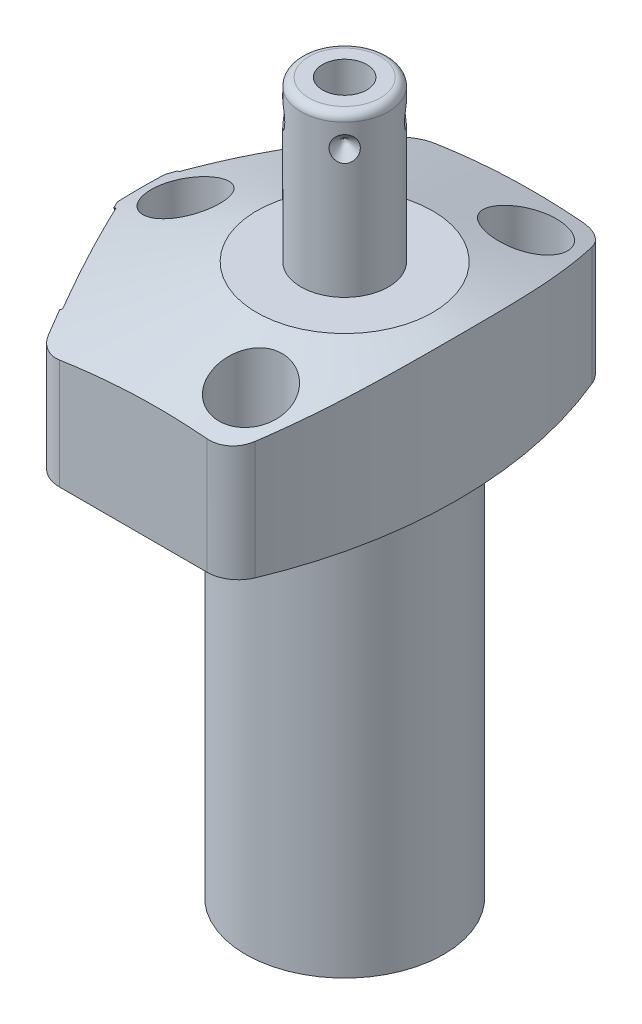
from build123d import *

# Parameters (mm, degrees)
CUT_EXTRUDE1_REACH = 21.05
CUT_EXTRUDE2_REACH = 21.05
S2D0002_OUTSIDE_W  = 78.27
S2D0002_OUTSIDE_H  = 69.906
CUT_EXTRUDE3_DEPTH = 26.035
FILLET1_R          = 3.9624
SKETCH17_R         = 10.4775
CUT_EXTRUDE4_DEPTH = 0.254
SKETCH18_R         = 10.4775
CUT_EXTRUDE5_DEPTH = 0.254
SKETCH19_R         = 5.5626
CUT_EXTRUDE6_DEPTH = 2.667
SKETCH12_R         = 4.8006
EXTRUDE1_DEPTH     = 1.651
EXTRUDE2_START     = -2.667
SKETCH13_R         = 4.8006
EXTRUDE2_DEPTH     = 2.667
CIRPATTERN1_COUNT  = 4
HOLE1_D            = 5.5626
HOLE1_DEPTH        = 19.05
HOLE1_CBORE_D      = 8.7122
HOLE1_CBORE_DEPTH  = 11.0998


with BuildPart() as part:
    # Sketch1 → Revolve1 (revolve)
    with BuildSketch(Plane(origin=(0, 0, 0), x_dir=(0, -1, 0), z_dir=(0, 0, 1)), mode=Mode.PRIVATE) as revolve1_sk:
        Polygon((0, 28.575), (-19.05, 28.575), (-19.05, 0), (50.8, 0), (50.8, 12.573), (0, 12.573), align=None)
    revolve(revolve1_sk.sketch.rotate(Axis((0, 22.5425, 0), (0, -1, 0)), 90), axis=Axis((0, 22.5425, 0), (0, -1, 0)))  # turned: the seam where the file's is

    # Sketch2 → Cut-Extrude1 (cut, up to next)
    with BuildSketch(Plane(origin=(0, 0, 0), x_dir=(0, 0, -1), z_dir=(0, -1, 0)), mode=Mode.PRIVATE) as cut_extrude1_sk1:
        with BuildLine():
            Line((23.8125, -15.795425564), (23.8125, 15.795425564))
            ThreePointArc((23.8125, 15.795425564), (28.575, 0), (23.8125, -15.795425564))
        make_face()
    cut_extrude1_tool1 = extrude(cut_extrude1_sk1.sketch, amount=-CUT_EXTRUDE1_REACH, mode=Mode.PRIVATE) & part.part
    add(cut_extrude1_tool1.solids().sort_by_distance((0, 0, -25.731798))[0], mode=Mode.SUBTRACT)
    # Sketch2 → Cut-Extrude1 (cut, up to next)
    with BuildSketch(Plane(origin=(0, 0, 0), x_dir=(0, 0, -1), z_dir=(0, -1, 0)), mode=Mode.PRIVATE) as cut_extrude1_sk2:
        with BuildLine():
            Line((-23.8125, 15.795425564), (-23.8125, -15.795425564))
            ThreePointArc((-23.8125, -15.795425564), (-28.575, 0), (-23.8125, 15.795425564))
        make_face()
    cut_extrude1_tool2 = extrude(cut_extrude1_sk2.sketch, amount=-CUT_EXTRUDE1_REACH, mode=Mode.PRIVATE) & part.part
    add(cut_extrude1_tool2.solids().sort_by_distance((0, 0, 25.731798))[0], mode=Mode.SUBTRACT)

    # Sketch3 → Cut-Extrude2 (cut, up to next)
    with BuildSketch(Plane(origin=(0, 0, 0), x_dir=(-1, 0, 0), z_dir=(0, -1, 0)), mode=Mode.PRIVATE) as cut_extrude2_sk1:
        with BuildLine():
            Line((14.75388632, 23.8125), (27.415217161, 0))
            Line((27.415217161, 0), (14.75388632, -23.8125))
            Line((14.75388632, -23.8125), (15.795425564, -23.8125))
            ThreePointArc((15.795425564, -23.8125), (28.575, 0), (15.795425564, 23.8125))
            Line((15.795425564, 23.8125), (14.75388632, 23.8125))
        make_face()
    cut_extrude2_tool1 = extrude(cut_extrude2_sk1.sketch, amount=-CUT_EXTRUDE2_REACH, mode=Mode.PRIVATE) & part.part
    add(cut_extrude2_tool1.solids().sort_by_distance((-15.274656, 0, -23.3166))[0], mode=Mode.SUBTRACT)

    # S2D0002 outside → Cut-Extrude3 (cut)
    with BuildSketch(Plane(origin=(0, 0, 0), x_dir=(-1, 0, 0), z_dir=(0, -1, 0))):
        with Locations((-0.58, 0)):
            Rectangle(S2D0002_OUTSIDE_W, S2D0002_OUTSIDE_H)
        with BuildLine():
            Line((25.8064, 53.379071452), (25.8064, -53.379071452))
            ThreePointArc((25.8064, -53.379071452), (-14.3002, 0), (25.8064, 53.379071452))
        make_face(mode=Mode.SUBTRACT)
    extrude(amount=-CUT_EXTRUDE3_DEPTH, mode=Mode.SUBTRACT)

    # Fillet1
    fillet1_edges = [part.edges().sort_by_distance(p)[0] for p in [
        (-14.75388632, 9.525, 23.8125),
        (-14.75388632, 9.525, -23.8125),
        (8.940213818, 9.525, 23.8125),
        (8.940213818, 9.525, -23.8125),
    ]]
    fillet(fillet1_edges, radius=FILLET1_R)

    # Sketch5 → Cut-Revolve1 (revolve, cut)
    with BuildSketch(Plane.XY, mode=Mode.PRIVATE) as cut_revolve1_sk:
        Polygon((-11.176, 19.05), (-44.45, 8.238622028), (-44.45, 19.05), align=None)
    revolve(cut_revolve1_sk.sketch.rotate(Axis((0, 5.998428823, 0), (0, 1, 0)), 90), axis=Axis((0, 5.998428823, 0), (0, 1, 0)), mode=Mode.SUBTRACT)  # turned: the seam where the file's is

    # Sketch6 → Cut-Revolve2 (revolve, cut)
    with BuildSketch(Plane(origin=(-21.148537334, 7.9502, -11.244876766), x_dir=(0.469471563, 0, -0.882947593), z_dir=(0, 1, 0))):
        Polygon((0, 0), (4.5466, 0), (4.106586662, -2.0701), (3.4544, -2.722286662), (3.4544, -12.192), (0, -12.192), align=None)
    revolve(axis=Axis((-9.845395429, 7.9502, -5.234889608), (-0.882947593, 0, -0.469471563)), mode=Mode.SUBTRACT)

    # Sketch7 → Cut-Revolve3 (revolve, cut)
    with BuildSketch(Plane(origin=(-21.148537334, 7.9502, 11.244876766), x_dir=(-0.469471563, 0, -0.882947593), z_dir=(0, 1, 0))):
        Polygon((0, 0), (4.5466, 0), (4.106586662, -2.0701), (3.4544, -2.722286662), (3.4544, -12.192), (0, -12.192), align=None)
    revolve(axis=Axis((-9.845395429, 7.9502, 5.234889608), (-0.882947593, 0, 0.469471563)), mode=Mode.SUBTRACT)

    # Sketch17 → Cut-Extrude4 (cut)
    with BuildSketch(Plane(origin=(-21.372806022, 0, 11.364122543), x_dir=(0.469471563, 0, 0.882947593), z_dir=(-0.882947593, 0, 0.469471563))):
        with Locations((0, 7.9502)):
            Circle(SKETCH17_R)
    extrude(amount=-CUT_EXTRUDE4_DEPTH, mode=Mode.SUBTRACT)

    # Sketch18 → Cut-Extrude5 (cut)
    with BuildSketch(Plane(origin=(-21.372806022, 0, -11.364122543), x_dir=(-0.469471563, 0, 0.882947593), z_dir=(-0.882947593, 0, -0.469471563))):
        with Locations((0, 7.9502)):
            Circle(SKETCH18_R)
    extrude(amount=-CUT_EXTRUDE5_DEPTH, mode=Mode.SUBTRACT)

    # Sketch8 → Cut-Revolve4 (revolve, cut)
    with BuildSketch(Plane(origin=(-11.1252, 2.667, -15.875), x_dir=(-1, 0, 0), z_dir=(0, 0, 1)), mode=Mode.PRIVATE) as cut_revolve4_sk:
        Polygon((0, 0), (4.5466, 0), (4.106586662, -2.0701), (3.4544, -2.722286662), (3.4544, -11.684), (0, -11.684), align=None)
    revolve(cut_revolve4_sk.sketch.rotate(Axis((-11.1252, 14.9352, -15.875), (0, -1, 0)), 270), axis=Axis((-11.1252, 14.9352, -15.875), (0, -1, 0)), mode=Mode.SUBTRACT)  # turned: the seam where the file's is

    # Sketch9 → Cut-Revolve5 (revolve, cut)
    with BuildSketch(Plane(origin=(-11.1252, 2.667, 15.875), x_dir=(-1, 0, 0), z_dir=(0, 0, 1)), mode=Mode.PRIVATE) as cut_revolve5_sk:
        Polygon((0, 0), (4.5466, 0), (4.106586662, -2.0701), (3.4544, -2.722286662), (3.4544, -11.684), (0, -11.684), align=None)
    revolve(cut_revolve5_sk.sketch.rotate(Axis((-11.1252, 14.9352, 15.875), (0, -1, 0)), 270), axis=Axis((-11.1252, 14.9352, 15.875), (0, -1, 0)), mode=Mode.SUBTRACT)  # turned: the seam where the file's is

    # Sketch10 → Revolve2 (revolve)
    with BuildSketch(Plane(origin=(0, 0, 0), x_dir=(0, 0, -1), z_dir=(1, 0, 0)), mode=Mode.PRIVATE) as revolve2_sk:
        with BuildLine():
            Line((0, 19.05), (-5.55625, 19.05))
            Line((-5.55625, 19.05), (-5.55625, 38.3032))
            ThreePointArc((-5.55625, 38.3032), (-5.25867049, 39.02162049), (-4.54025, 39.3192))
            Line((-4.54025, 39.3192), (0, 39.3192))
            Line((0, 39.3192), (0, 19.05))
        make_face()
    revolve(revolve2_sk.sketch.rotate(Axis((0, 18.03654, 0), (0, 1, 0)), 180), axis=Axis((0, 18.03654, 0), (0, 1, 0)))  # turned: the seam where the file's is

    # Sketch19 → Cut-Extrude6 (cut)
    with BuildSketch(Plane.XZ):
        with Locations(Location((-11.1252, -15.875, 0), (0, 0, 270))):  # turned: the seam where the file's is
            Circle(SKETCH19_R)
        with Locations(Location((-11.1252, 15.875, 0), (0, 0, 270))):  # turned: the seam where the file's is
            Circle(SKETCH19_R)
    extrude(amount=-CUT_EXTRUDE6_DEPTH, mode=Mode.SUBTRACT)

    # S2D0001 → Cut-Revolve6 (revolve, cut)
    with BuildSketch(Plane(origin=(2.8067, 39.3192, 0), x_dir=(1, 0, 0), z_dir=(0, 0, 1)), mode=Mode.PRIVATE) as cut_revolve6_sk:
        Polygon((0, 0), (0, -10.16), (-2.8067, -11.846435499), (-2.8067, 0), align=None)
    revolve(cut_revolve6_sk.sketch.rotate(Axis((0, 21.752471385, 0), (0, 1, 0)), 90), axis=Axis((0, 21.752471385, 0), (0, 1, 0)), mode=Mode.SUBTRACT)  # turned: the seam where the file's is

    # Sketch12 → Extrude1 (add)
    with BuildSketch(Plane(origin=(-21.148537334, 0, -11.244876766), x_dir=(0.469471563, 0, -0.882947593), z_dir=(0.882947593, 0, 0.469471563))):
        with Locations((0, 7.9502)):
            Circle(SKETCH12_R)
    extrude(amount=-EXTRUDE1_DEPTH)

    # Sketch13 → Extrude2 (add)
    with BuildSketch(Plane.XZ.offset(EXTRUDE2_START)):
        with Locations(Location((-11.1252, -15.875, 0), (0, 0, 270))):  # turned: the seam where the file's is
            Circle(SKETCH13_R)
    extrude(amount=EXTRUDE2_DEPTH)

    # Sketch14 → Revolve3 (revolve)
    with BuildSketch(Plane(origin=(-11.1252, 0, 15.875), x_dir=(0, 0, -1), z_dir=(1, 0, 0))):
        with BuildLine():
            Line((5.461, 2.667), (5.461, 0.9398))
            Line((5.461, 0.9398), (5.301559456, 0.9398))
            ThreePointArc((5.301559456, 0.9398), (4.572, -0.4572), (3.842440544, 0.9398))
            Line((3.842440544, 0.9398), (3.175, 0.9398))
            ThreePointArc((3.175, 0.9398), (2.815789755, 0.791010245), (2.667, 0.4318))
            Line((2.667, 0.4318), (2.667, 0.127))
            Line((2.667, 0.127), (1.5875, 0.127))
            Line((1.5875, 0.127), (1.5875, 10.6172))
            Line((1.5875, 10.6172), (3.2512, 10.6172))
            Line((3.2512, 10.6172), (3.2512, 2.667))
            Line((3.2512, 2.667), (5.461, 2.667))
        make_face()
    revolve(axis=Axis((-11.1252, -1.01092, 15.875), (0, 1, 0)))

    # Sketch15 → Cut-Revolve7 (revolve, cut)
    with BuildSketch(Plane(origin=(-3.928862053, 35.3568, -3.928862053), x_dir=(0, 1, 0), z_dir=(-0.707106781, 0, 0.707106781)), mode=Mode.PRIVATE) as cut_revolve7_sk:
        Polygon((0, 0), (1.5875, 0), (0, -1.5875), align=None)
    cut_revolve7 = revolve(cut_revolve7_sk.sketch.rotate(Axis((-1.311312804, 35.3568, -1.311312804), (-0.707106781, 0, -0.707106781)), 270), axis=Axis((-1.311312804, 35.3568, -1.311312804), (-0.707106781, 0, -0.707106781)), mode=Mode.SUBTRACT)  # turned: the seam where the file's is

    # CirPattern1: Cut-Revolve7 ×4 about axis
    cirpattern1_axis = Axis((0, 18.03654, 0), (0, -1, 0))
    for i in range(1, CIRPATTERN1_COUNT):
        add(cut_revolve7.rotate(cirpattern1_axis, i * 360 / CIRPATTERN1_COUNT), mode=Mode.SUBTRACT)

    # Hole1
    with Locations(Plane(origin=(0, 19.05, 0), x_dir=(-1, 0, 0), z_dir=(0, 1, 0))):
        with Locations((-5.5626, -17.4498), (20.193, 0), (-5.5626, 17.4498)):
            CounterBoreHole(HOLE1_D / 2, HOLE1_CBORE_D / 2, HOLE1_CBORE_DEPTH, depth=HOLE1_DEPTH)


solid = part.part
